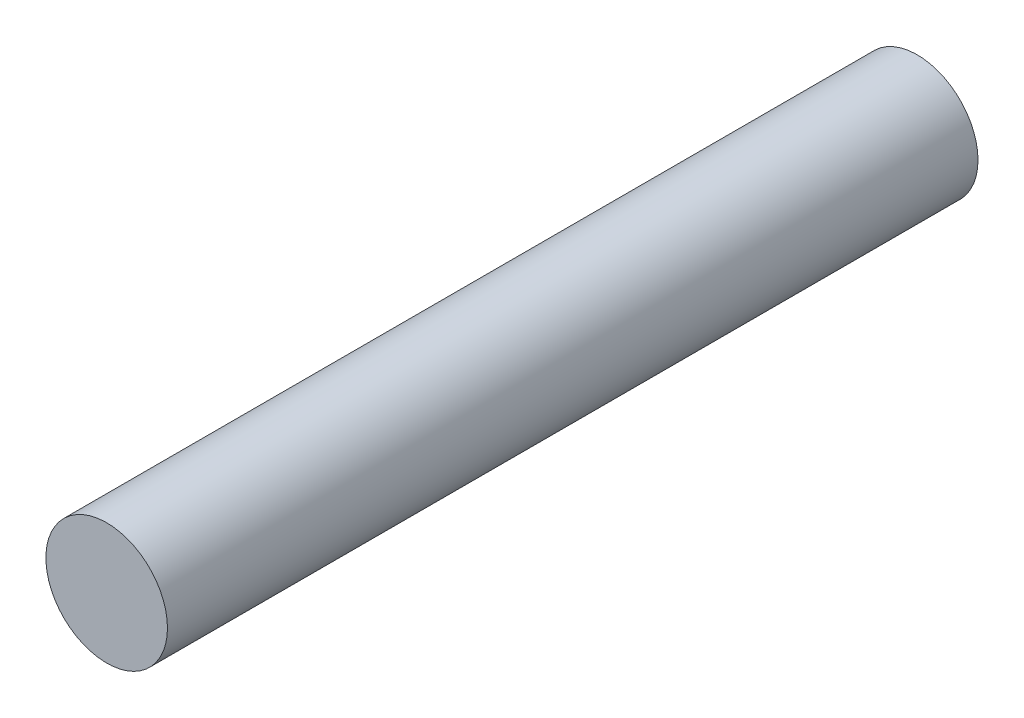
from build123d import *

# Parameters (mm, degrees)
SKETCH1_R           = 1.5
BOSS_EXTRUDE1_DEPTH = 20


with BuildPart() as part:
    # Sketch1 → Boss-Extrude1 (new body)
    with BuildSketch(Plane.XY):
        Circle(SKETCH1_R)
    extrude(amount=BOSS_EXTRUDE1_DEPTH)


solid = part.part
